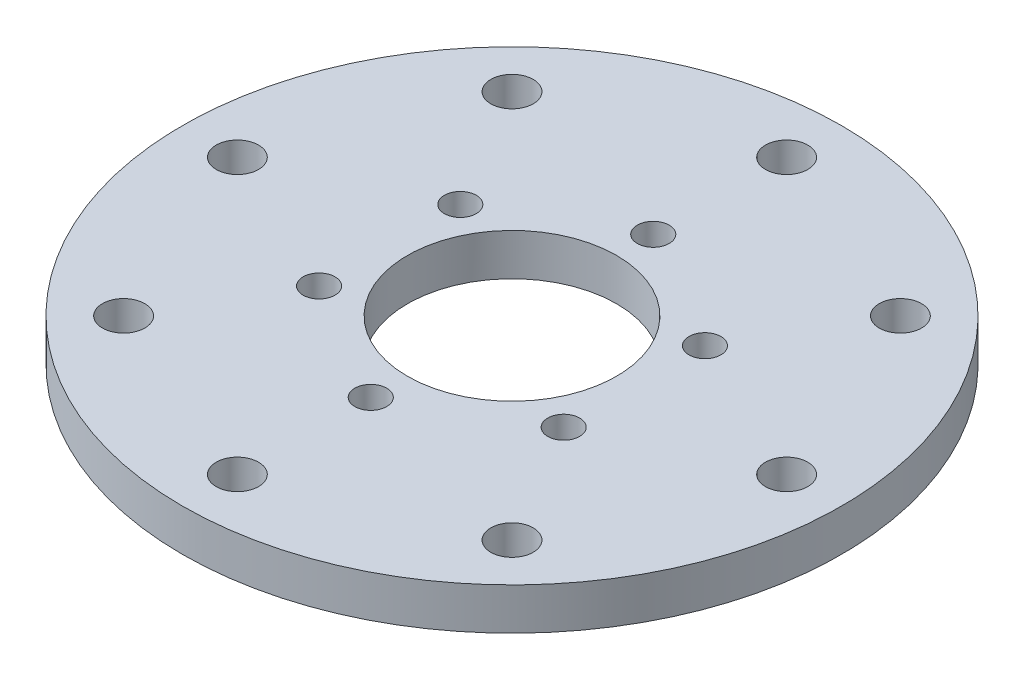
from build123d import *

# Parameters (mm, degrees)
SKETCH_1_R               = 31.5
SKETCH_1_R_2             = 22.5
EXTRUDE_1_DEPTH          = 4
SKETCH_2_R               = 2.025
CUT_EXTRUDE_1_DEPTH      = 1
CUT_EXTRUDE_1_DEPTH_BACK = 5
SKETCH_3_R               = 22.5
EXTRUDE_2_DEPTH          = 4
SKETCH_4_R               = 1.525
CUT_EXTRUDE_2_DEPTH      = 4
SKETCH_5_R               = 10
CUT_EXTRUDE_3_DEPTH      = 4


with BuildPart() as part:
    # 草图1 → 凸台-拉伸1 (new body)
    with BuildSketch(Plane(origin=(0, 0, 0), x_dir=(1, 0, 0), z_dir=(0, 1, 0))):
        Circle(SKETCH_1_R)
        Circle(SKETCH_1_R_2, mode=Mode.SUBTRACT)
    extrude(amount=EXTRUDE_1_DEPTH)

    # 草图2 → 切除-拉伸1 (cut, two sides)
    with BuildSketch(Plane(origin=(0, 4, 0), x_dir=(1, 0, 0), z_dir=(0, 1, 0))) as cut_extrude_1_sk:
        with Locations((0, 26.25)):
            Circle(SKETCH_2_R)
        with Locations((18.561553006, 18.561553006)):
            Circle(SKETCH_2_R)
        with Locations((26.25, 0)):
            Circle(SKETCH_2_R)
        with Locations((18.561553006, -18.561553006)):
            Circle(SKETCH_2_R)
        with Locations((0, -26.25)):
            Circle(SKETCH_2_R)
        with Locations((-18.561553006, -18.561553006)):
            Circle(SKETCH_2_R)
        with Locations((-26.25, 0)):
            Circle(SKETCH_2_R)
        with Locations((-18.561553006, 18.561553006)):
            Circle(SKETCH_2_R)
    extrude(amount=CUT_EXTRUDE_1_DEPTH, mode=Mode.SUBTRACT)
    extrude(cut_extrude_1_sk.sketch, amount=-CUT_EXTRUDE_1_DEPTH_BACK, mode=Mode.SUBTRACT)

    # 草图3 → 凸台-拉伸2 (add)
    with BuildSketch(Plane(origin=(0, 4, 0), x_dir=(1, 0, 0), z_dir=(0, 1, 0))):
        Circle(SKETCH_3_R)
    extrude(amount=-EXTRUDE_2_DEPTH)

    # 草图4 → 切除-拉伸2 (cut)
    with BuildSketch(Plane.XZ):
        with Locations((0, 13.5)):
            Circle(SKETCH_4_R)
        with Locations((11.691342951, 6.75)):
            Circle(SKETCH_4_R)
        with Locations((11.691342951, -6.75)):
            Circle(SKETCH_4_R)
        with Locations((0, -13.5)):
            Circle(SKETCH_4_R)
        with Locations((-11.691342951, -6.75)):
            Circle(SKETCH_4_R)
        with Locations((-11.691342951, 6.75)):
            Circle(SKETCH_4_R)
    extrude(amount=-CUT_EXTRUDE_2_DEPTH, mode=Mode.SUBTRACT)

    # 草图5 → 切除-拉伸3 (cut)
    with BuildSketch(Plane.XZ):
        Circle(SKETCH_5_R)
    extrude(amount=-CUT_EXTRUDE_3_DEPTH, mode=Mode.SUBTRACT)


solid = part.part
